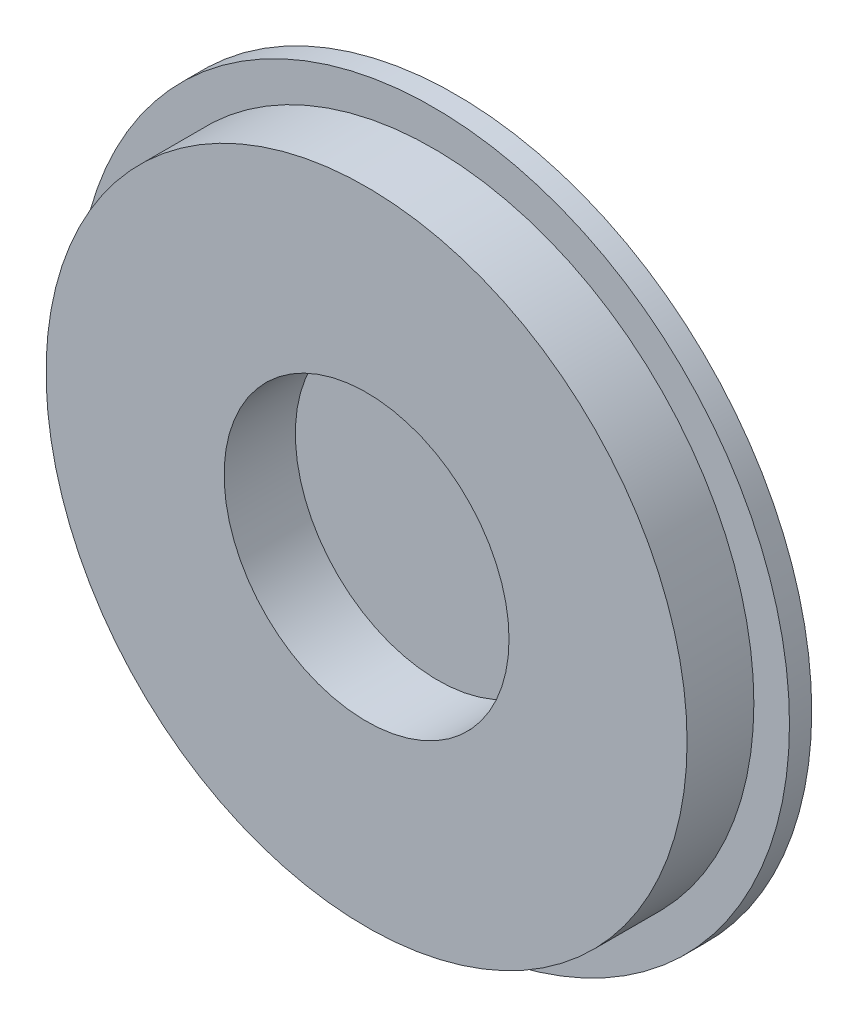
from build123d import *

# Parameters (mm, degrees)
SKETCH1_R           = 20
BOSS_EXTRUDE1_DEPTH = 1.25
SKETCH2_R           = 18
BOSS_EXTRUDE2_DEPTH = 3.75
SKETCH3_R           = 8
CUT_EXTRUDE1_DEPTH  = 4


with BuildPart() as part:
    # Sketch1 → Boss-Extrude1 (new body)
    with BuildSketch(Plane.XY):
        Circle(SKETCH1_R)
    extrude(amount=BOSS_EXTRUDE1_DEPTH)

    # Sketch2 → Boss-Extrude2 (add)
    with BuildSketch(Plane.XY.offset(1.25)):
        Circle(SKETCH2_R)
    extrude(amount=BOSS_EXTRUDE2_DEPTH)

    # Sketch3 → Cut-Extrude1 (cut)
    with BuildSketch(Plane.XY.offset(5)):
        Circle(SKETCH3_R)
    extrude(amount=-CUT_EXTRUDE1_DEPTH, mode=Mode.SUBTRACT)


solid = part.part
